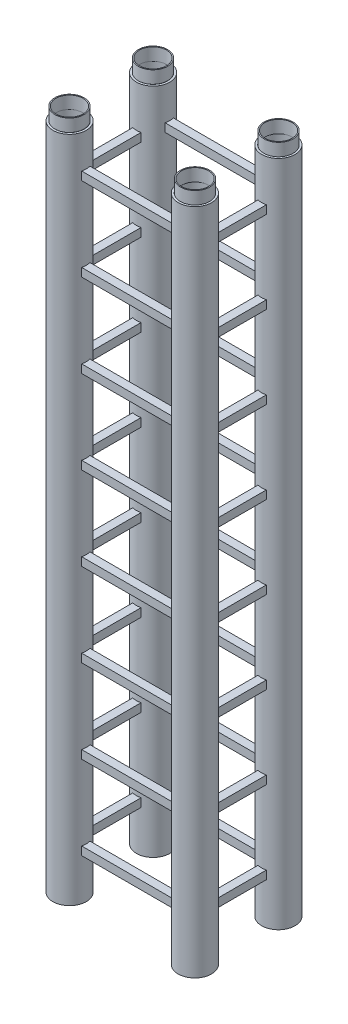
from build123d import *

# Parameters (mm, degrees)
SKETCH1_R                = 200
SKETCH1_R_2              = 175
BOSS_EXTRUDE1_DEPTH      = 8000
BOSS_EXTRUDE1_2_DEPTH    = 8000
BOSS_EXTRUDE1_3_DEPTH    = 8000
BOSS_EXTRUDE1_4_DEPTH    = 8000
SKETCH2_R                = 175
SKETCH2_R_2              = 162.5
BOSS_EXTRUDE2_DEPTH      = 150
SKETCH3_W                = 730
SKETCH3_H                = 100
BOSS_EXTRUDE3_DEPTH      = 50
BOSS_EXTRUDE3_DEPTH_BACK = 50
SKETCH4_W                = 730
SKETCH4_H                = 100
BOSS_EXTRUDE4_DEPTH      = 50
BOSS_EXTRUDE4_DEPTH_BACK = 50
SKETCH5_W                = 1200
SKETCH5_H                = 100
BOSS_EXTRUDE6_DEPTH      = 50
BOSS_EXTRUDE6_DEPTH_BACK = 50
SKETCH6_W                = 1112.70166538
SKETCH6_H                = 100
BOSS_EXTRUDE7_DEPTH      = 50
BOSS_EXTRUDE7_DEPTH_BACK = 50


with BuildPart() as part:
    # Sketch1 → Boss-Extrude1 (new body)
    with BuildSketch(Plane(origin=(0, 0, 0), x_dir=(1, 0, 0), z_dir=(0, 1, 0))):
        with Locations((-750, 500)):
            Circle(SKETCH1_R)
        with Locations((-750, 500)):
            Circle(SKETCH1_R_2, mode=Mode.SUBTRACT)
    extrude(amount=BOSS_EXTRUDE1_DEPTH)



with BuildPart() as body_2:
    # Sketch1 → Boss-Extrude1 2 (new body)
    with BuildSketch(Plane(origin=(0, 0, 0), x_dir=(1, 0, 0), z_dir=(0, 1, 0))):
        with Locations((750, 500)):
            Circle(SKETCH1_R)
        with Locations((750, 500)):
            Circle(SKETCH1_R_2, mode=Mode.SUBTRACT)
    extrude(amount=BOSS_EXTRUDE1_2_DEPTH)


with BuildPart() as body_3:
    # Sketch1 → Boss-Extrude1 3 (new body)
    with BuildSketch(Plane(origin=(0, 0, 0), x_dir=(1, 0, 0), z_dir=(0, 1, 0))):
        with Locations((750, -500)):
            Circle(SKETCH1_R)
        with Locations((750, -500)):
            Circle(SKETCH1_R_2, mode=Mode.SUBTRACT)
    extrude(amount=BOSS_EXTRUDE1_3_DEPTH)


with BuildPart() as body_4:
    # Sketch1 → Boss-Extrude1 4 (new body)
    with BuildSketch(Plane(origin=(0, 0, 0), x_dir=(1, 0, 0), z_dir=(0, 1, 0))):
        with Locations((-750, -500)):
            Circle(SKETCH1_R)
        with Locations((-750, -500)):
            Circle(SKETCH1_R_2, mode=Mode.SUBTRACT)
    extrude(amount=BOSS_EXTRUDE1_4_DEPTH)


with BuildPart() as part_1:
    add(part.part)

    add(body_2.part)  # Boss-Extrude2 merges body 2

    add(body_3.part)  # Boss-Extrude2 merges body 3

    add(body_4.part)  # Boss-Extrude2 merges body 4
    # Sketch2 → Boss-Extrude2 (add)
    with BuildSketch(Plane(origin=(0, 8000, 0), x_dir=(1, 0, 0), z_dir=(0, 1, 0))):
        with Locations((-751.952146148, 500)):
            Circle(SKETCH2_R)
        with Locations((-751.952146148, 500)):
            Circle(SKETCH2_R_2, mode=Mode.SUBTRACT)
        with Locations((751.952146148, 500)):
            Circle(SKETCH2_R)
        with Locations((751.952146148, 500)):
            Circle(SKETCH2_R_2, mode=Mode.SUBTRACT)
        with Locations((751.952146148, -500)):
            Circle(SKETCH2_R)
        with Locations((751.952146148, -500)):
            Circle(SKETCH2_R_2, mode=Mode.SUBTRACT)
        with Locations((-751.952146148, -500)):
            Circle(SKETCH2_R)
        with Locations((-751.952146148, -500)):
            Circle(SKETCH2_R_2, mode=Mode.SUBTRACT)
    extrude(amount=BOSS_EXTRUDE2_DEPTH)

    # Sketch3 → Boss-Extrude3 (add, two sides)
    with BuildSketch(Plane(origin=(750, 0, 0), x_dir=(0, 0, -1), z_dir=(1, 0, 0))) as boss_extrude3_sk:
        with Locations((0, 550)):
            Rectangle(SKETCH3_W, SKETCH3_H)
        with Locations((0, 1535.714285714)):
            Rectangle(SKETCH3_W, SKETCH3_H)
        with Locations((0, 2521.428571429)):
            Rectangle(SKETCH3_W, SKETCH3_H)
        with Locations((0, 3507.142857143)):
            Rectangle(SKETCH3_W, SKETCH3_H)
        with Locations((0, 4492.857142857)):
            Rectangle(SKETCH3_W, SKETCH3_H)
        with Locations((0, 5478.571428571)):
            Rectangle(SKETCH3_W, SKETCH3_H)
        with Locations((0, 6464.285714286)):
            Rectangle(SKETCH3_W, SKETCH3_H)
        with Locations((0, 7450)):
            Rectangle(SKETCH3_W, SKETCH3_H)
    extrude(amount=BOSS_EXTRUDE3_DEPTH)
    extrude(boss_extrude3_sk.sketch, amount=-BOSS_EXTRUDE3_DEPTH_BACK)

    # Sketch4 → Boss-Extrude4 (add, two sides)
    with BuildSketch(Plane(origin=(-750, 0, 0), x_dir=(0, 0, -1), z_dir=(1, 0, 0))) as boss_extrude4_sk:
        with Locations((0, 550)):
            Rectangle(SKETCH4_W, SKETCH4_H)
        with Locations((0, 1535.714285714)):
            Rectangle(SKETCH4_W, SKETCH4_H)
        with Locations((0, 2521.428571429)):
            Rectangle(SKETCH4_W, SKETCH4_H)
        with Locations((0, 3507.142857143)):
            Rectangle(SKETCH4_W, SKETCH4_H)
        with Locations((0, 4492.857142857)):
            Rectangle(SKETCH4_W, SKETCH4_H)
        with Locations((0, 5478.571428571)):
            Rectangle(SKETCH4_W, SKETCH4_H)
        with Locations((0, 6464.285714286)):
            Rectangle(SKETCH4_W, SKETCH4_H)
        with Locations((0, 7450)):
            Rectangle(SKETCH4_W, SKETCH4_H)
    extrude(amount=BOSS_EXTRUDE4_DEPTH)
    extrude(boss_extrude4_sk.sketch, amount=-BOSS_EXTRUDE4_DEPTH_BACK)

    # Sketch5 → Boss-Extrude6 (add, two sides)
    with BuildSketch(Plane.XY.offset(500)) as boss_extrude6_sk:
        with Locations((0, 550)):
            Rectangle(SKETCH5_W, SKETCH5_H)
        with Locations((0, 1550)):
            Rectangle(SKETCH5_W, SKETCH5_H)
        with Locations((0, 2550)):
            Rectangle(SKETCH5_W, SKETCH5_H)
        with Locations((0, 3550)):
            Rectangle(SKETCH5_W, SKETCH5_H)
        with Locations((0, 4550)):
            Rectangle(SKETCH5_W, SKETCH5_H)
        with Locations((0, 5550)):
            Rectangle(SKETCH5_W, SKETCH5_H)
        with Locations((0, 6550)):
            Rectangle(SKETCH5_W, SKETCH5_H)
        with Locations((0, 7550)):
            Rectangle(SKETCH5_W, SKETCH5_H)
    extrude(amount=BOSS_EXTRUDE6_DEPTH)
    extrude(boss_extrude6_sk.sketch, amount=-BOSS_EXTRUDE6_DEPTH_BACK)

    # Sketch6 → Boss-Extrude7 (add, two sides)
    with BuildSketch(Plane.XY.offset(-500)) as boss_extrude7_sk:
        with Locations((0, 550)):
            Rectangle(SKETCH6_W, SKETCH6_H)
        with Locations((0, 1550)):
            Rectangle(SKETCH6_W, SKETCH6_H)
        with Locations((0, 2550)):
            Rectangle(SKETCH6_W, SKETCH6_H)
        with Locations((0, 3550)):
            Rectangle(SKETCH6_W, SKETCH6_H)
        with Locations((0, 4550)):
            Rectangle(SKETCH6_W, SKETCH6_H)
        with Locations((0, 5550)):
            Rectangle(SKETCH6_W, SKETCH6_H)
        with Locations((0, 6550)):
            Rectangle(SKETCH6_W, SKETCH6_H)
        with Locations((0, 7550)):
            Rectangle(SKETCH6_W, SKETCH6_H)
    extrude(amount=BOSS_EXTRUDE7_DEPTH)
    extrude(boss_extrude7_sk.sketch, amount=-BOSS_EXTRUDE7_DEPTH_BACK)


solid = part_1.part
